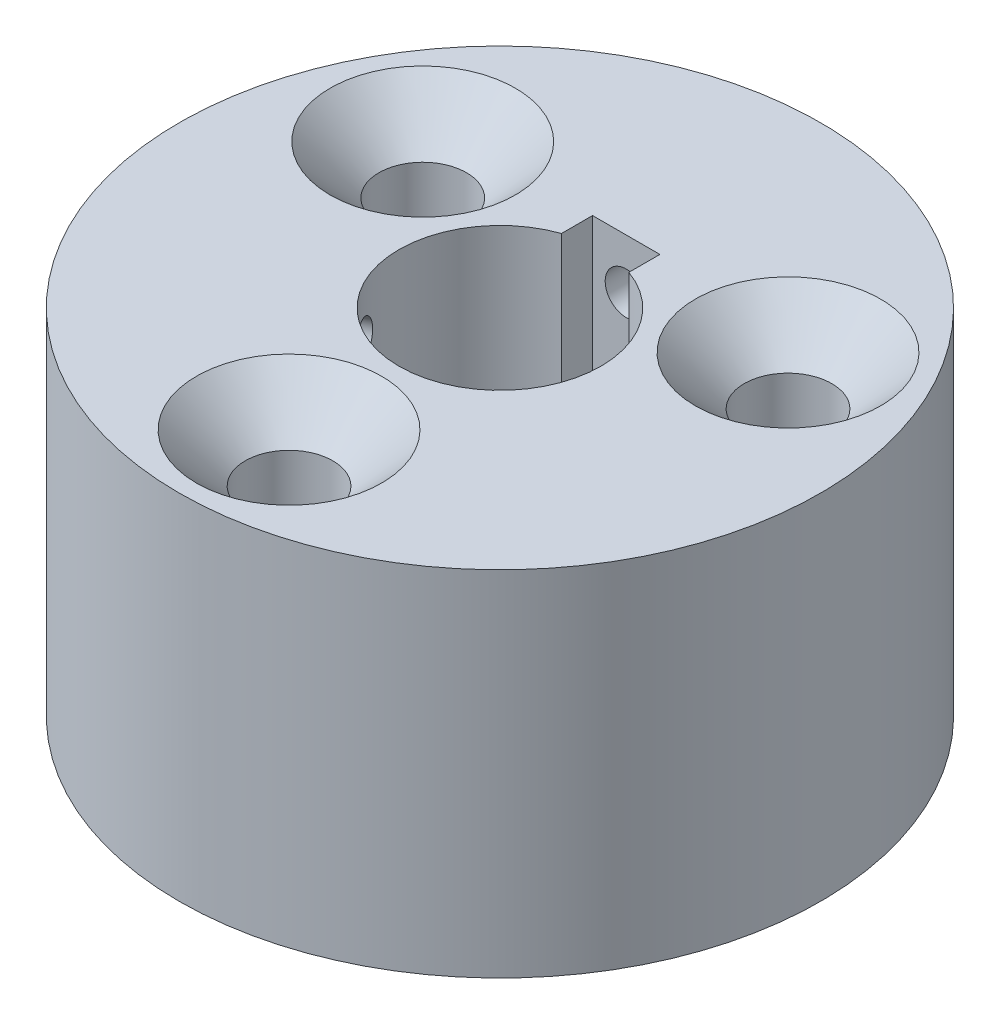
from build123d import *

# Parameters (mm, degrees)
SKETCH1_R                     = 19.05
SKETCH1_R_2                   = 2.5
BOSS_EXTRUDE1_DEPTH           = 21
SKETCH2_R                     = 1.25
CUT_EXTRUDE1_DEPTH            = 3
CUT_EXTRUDE1_DEPTH_BACK       = 15
SKETCH4_R                     = 1.25
CUT_EXTRUDE2_DEPTH            = 20
CSK_FOR_M5_SFHCS1_D           = 5.2
CSK_FOR_M5_SFHCS1_CSINK_D     = 11
CSK_FOR_M5_SFHCS1_CSINK_ANGLE = 90


with BuildPart() as part:
    # Sketch1 → Boss-Extrude1 (new body)
    with BuildSketch(Plane(origin=(0, 0, 0), x_dir=(1, 0, 0), z_dir=(0, 1, 0))):
        Circle(SKETCH1_R)
        with Locations((0, -12.525)):
            Circle(SKETCH1_R_2, mode=Mode.SUBTRACT)
        with Locations((-10.846968182, 6.2625)):
            Circle(SKETCH1_R_2, mode=Mode.SUBTRACT)
        with BuildLine():
            Line((-2, 5.656854249), (-2, 7.5))
            Line((-2, 7.5), (-1, 7.5))
            Line((-1, 7.5), (1, 7.5))
            Line((1, 7.5), (2, 7.5))
            Line((2, 7.5), (2, 5.656854249))
            ThreePointArc((2, 5.656854249), (4.898979486, 3.464101615), (6, 0))
            ThreePointArc((6, 0), (-3.464101615, -4.898979486), (-2, 5.656854249))
        make_face(mode=Mode.SUBTRACT)
        with Locations((10.846968182, 6.2625)):
            Circle(SKETCH1_R_2, mode=Mode.SUBTRACT)
        with Locations((-10.846968182, 6.2625)):
            Circle(SKETCH1_R_2)
        with Locations((10.846968182, 6.2625)):
            Circle(SKETCH1_R_2)
        with Locations((0, -12.525)):
            Circle(SKETCH1_R_2)
    extrude(amount=BOSS_EXTRUDE1_DEPTH)

    # Sketch2 → Cut-Extrude1 (cut, two sides)
    with BuildSketch(Plane.XY.offset(-7.5)) as cut_extrude1_sk:
        with Locations((0, 18)):
            Circle(SKETCH2_R)
    extrude(amount=CUT_EXTRUDE1_DEPTH, mode=Mode.SUBTRACT)
    extrude(cut_extrude1_sk.sketch, amount=-CUT_EXTRUDE1_DEPTH_BACK, mode=Mode.SUBTRACT)

    # Sketch4 → Cut-Extrude2 (cut)
    with BuildSketch(Plane(origin=(0, 0, 0), x_dir=(0, -1, 0), z_dir=(-0.866025404, 0, 0.5))):
        with Locations((-18, 0)):
            Circle(SKETCH4_R)
    extrude(amount=CUT_EXTRUDE2_DEPTH, mode=Mode.SUBTRACT)

    # CSK for M5 SFHCS1 (through all)
    with Locations(Plane(origin=(0, 21, 0), x_dir=(1, 0, 0), z_dir=(0, 1, 0))):
        with Locations((10.846968182, 6.2625), (0, -12.525), (-10.846968182, 6.2625), (0, 0)):
            CounterSinkHole(CSK_FOR_M5_SFHCS1_D / 2, CSK_FOR_M5_SFHCS1_CSINK_D / 2, counter_sink_angle=CSK_FOR_M5_SFHCS1_CSINK_ANGLE)


solid = part.part
